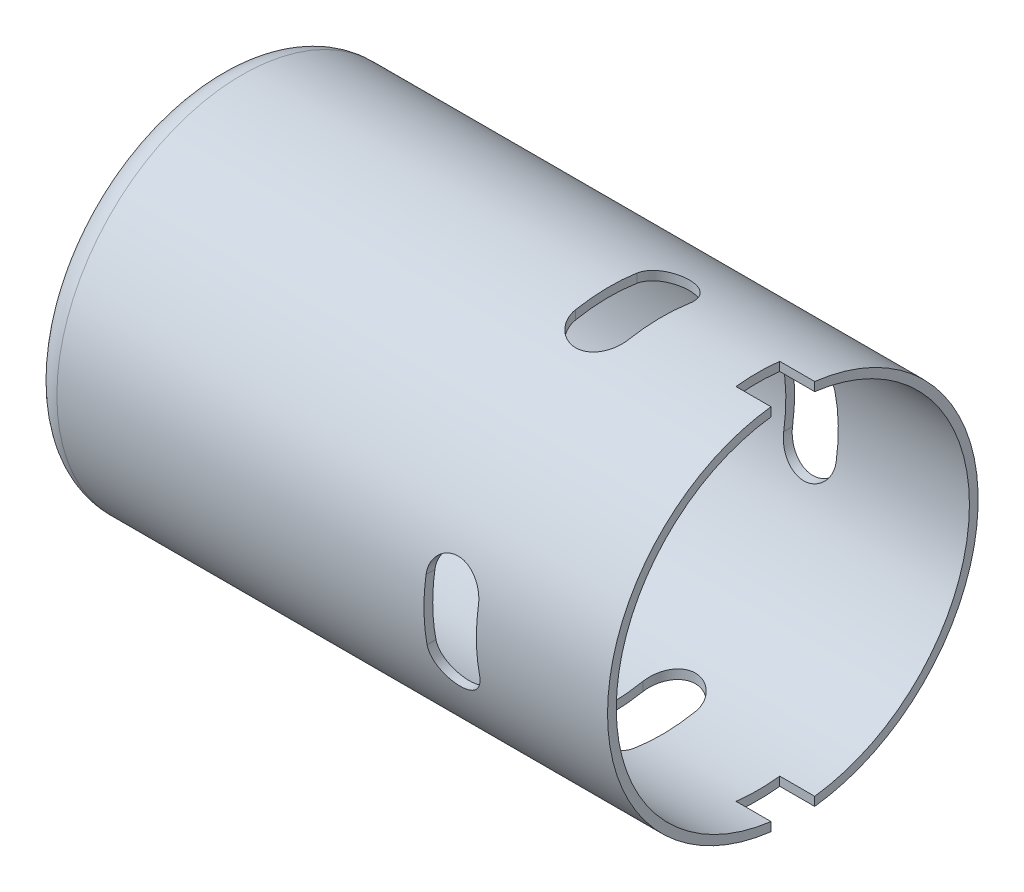
from build123d import *

# Parameters (mm, degrees)
CUT_EXTRUDE6_REACH      = 87.122
CUT_EXTRUDE6_END_RADIUS = 20.2
CIRPATTERN21_COUNT      = 4
SKETCH10_W              = 4
SKETCH10_H              = 5
CUT_EXTRUDE7_DEPTH      = 10
CIRPATTERN22_COUNT      = 2
CUT_EXTRUDE8_REACH      = 74.491
SKETCH13_R              = 2


with BuildPart() as part:
    # Sketch1 → Revolve2 (revolve)
    with BuildSketch(Plane.XY, mode=Mode.PRIVATE) as revolve2_sk:
        with BuildLine():
            Line((70.7, 21.2), (7.7, 21.2))
            ThreePointArc((7.7, 21.2), (5.578679656, 20.321320344), (4.7, 18.2))
            Line((4.7, 18.2), (4.7, 10))
            ThreePointArc((4.7, 10), (4.407106781, 9.292893219), (3.7, 9))
            Line((3.7, 9), (0, 9))
            Line((0, 9), (0, 8))
            Line((0, 8), (4.7, 8))
            Line((4.7, 8), (4.7, 5.5))
            Line((4.7, 5.5), (5.7, 5.5))
            Line((5.7, 5.5), (5.7, 8))
            Line((5.7, 8), (5.7, 18.2))
            ThreePointArc((5.7, 18.2), (6.285786438, 19.614213562), (7.7, 20.2))
            Line((7.7, 20.2), (70.7, 20.2))
            Line((70.7, 20.2), (70.7, 21.2))
        make_face()
    revolve(revolve2_sk.sketch.rotate(Axis((0, 0, 0), (1, 0, 0)), 90), axis=Axis((0, 0, 0), (1, 0, 0)))

    # Cut-Extrude6: up to this cylinder (the profile starts outside it)
    cut_extrude6_end = Plane(origin=(52.7, 0, 0), z_dir=(-1, 0, 0)) * Cylinder(CUT_EXTRUDE6_END_RADIUS, 215.644, mode=Mode.PRIVATE)
    # Sketch8 → Cut-Extrude6 (cut, up to the surface)
    with BuildSketch(Plane(origin=(70.7, 21.2, 0), x_dir=(1, 0, 0), z_dir=(0, 1, 0)), mode=Mode.PRIVATE) as cut_extrude6_sk1:
        with BuildLine():
            Line((-15, 3.153060045), (-15, -3.846939955))
            ThreePointArc((-15, -3.846939955), (-18, -6.846939955), (-21, -3.846939955))
            Line((-21, -3.846939955), (-21, 3.153060045))
            ThreePointArc((-21, 3.153060045), (-18, 6.153060045), (-15, 3.153060045))
        make_face()
    cut_extrude6_tool1 = extrude(cut_extrude6_sk1.sketch, amount=-CUT_EXTRUDE6_REACH, mode=Mode.PRIVATE) - cut_extrude6_end
    cut_extrude6 = cut_extrude6_tool1.solids().sort_by_distance((52.7, 21.2, 0.34694))[0]
    add(cut_extrude6, mode=Mode.SUBTRACT)

    # CirPattern21: Cut-Extrude6 ×4 about axis
    cirpattern21_axis = Axis((0, 0, 0), (-1, 0, 0))
    for i in range(1, CIRPATTERN21_COUNT):
        add(cut_extrude6.rotate(cirpattern21_axis, i * 360 / CIRPATTERN21_COUNT), mode=Mode.SUBTRACT)

    # Sketch10 → Cut-Extrude7 (cut)
    with BuildSketch(Plane(origin=(70.7, 21.2, 0), x_dir=(1, 0, 0), z_dir=(0, 1, 0))):
        with Locations((-2, 0)):
            Rectangle(SKETCH10_W, SKETCH10_H)
    cut_extrude7 = extrude(amount=-CUT_EXTRUDE7_DEPTH, mode=Mode.SUBTRACT)

    # CirPattern22: Cut-Extrude7 ×2 about axis
    cirpattern22_axis = Axis((0, 0, 0), (-1, 0, 0))
    for i in range(1, CIRPATTERN22_COUNT):
        add(cut_extrude7.rotate(cirpattern22_axis, i * 360 / CIRPATTERN22_COUNT), mode=Mode.SUBTRACT)

    # Sketch13 → Cut-Extrude8 (cut, up to next)
    with BuildSketch(Plane.ZY.offset(-4.7), mode=Mode.PRIVATE) as cut_extrude8_sk1:
        with Locations((10.253048327, 10.253048327)):
            Circle(SKETCH13_R)
    cut_extrude8_tool1 = extrude(cut_extrude8_sk1.sketch, amount=-CUT_EXTRUDE8_REACH, mode=Mode.PRIVATE) & part.part
    # Sketch13 → Cut-Extrude8 (cut, up to next)
    with BuildSketch(Plane.ZY.offset(-4.7), mode=Mode.PRIVATE) as cut_extrude8_sk2:
        with Locations((-10.253048327, -10.253048327)):
            Circle(SKETCH13_R)
    cut_extrude8_tool2 = extrude(cut_extrude8_sk2.sketch, amount=-CUT_EXTRUDE8_REACH, mode=Mode.PRIVATE) & part.part
    add(cut_extrude8_tool1.solids().sort_by_distance((4.7, 10.253048, 10.253048))[0], mode=Mode.SUBTRACT)
    add(cut_extrude8_tool2.solids().sort_by_distance((4.7, -10.253048, -10.253048))[0], mode=Mode.SUBTRACT)


solid = part.part
